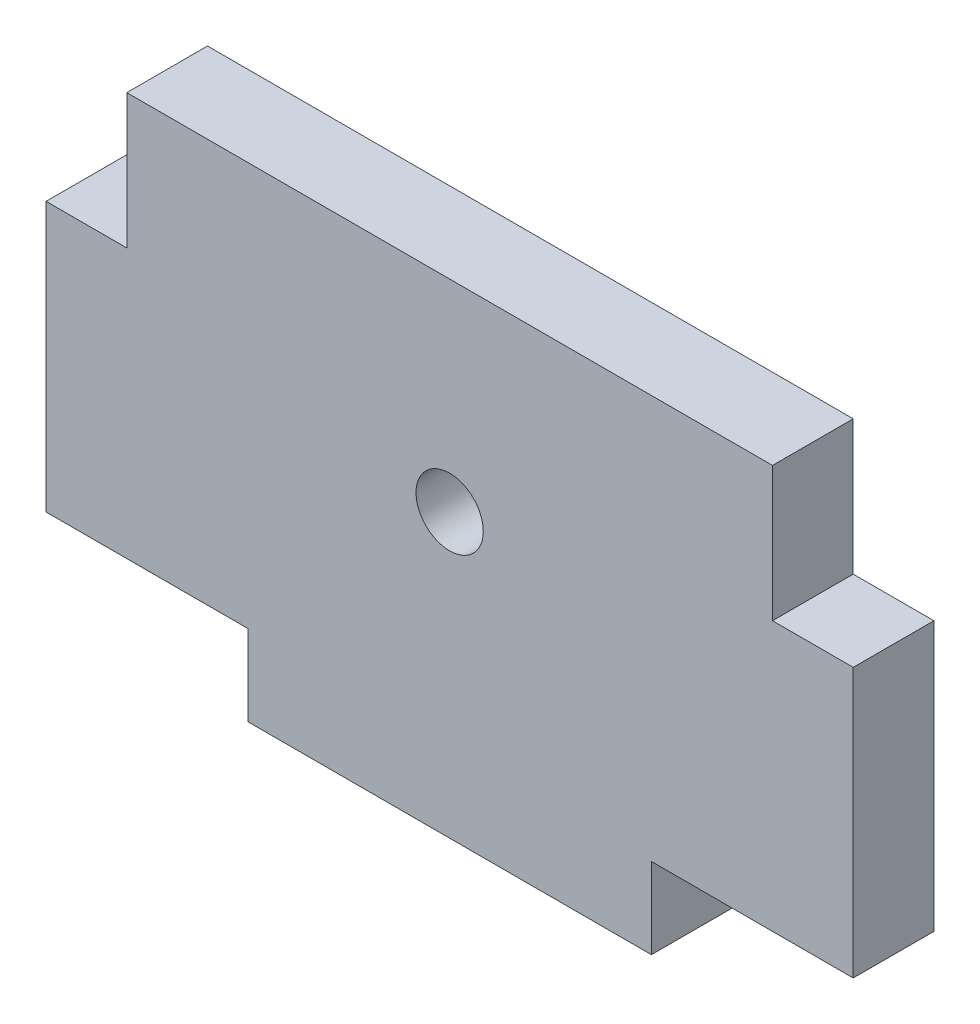
from build123d import *

# Parameters (mm, degrees)
SKETCH1_W           = 60
SKETCH1_H           = 36
BOSS_EXTRUDE1_DEPTH = 6
SKETCH2_W           = 15
SKETCH2_H           = 6
CUT_EXTRUDE1_DEPTH  = 6
SKETCH3_W           = 6
SKETCH3_H           = 10
CUT_EXTRUDE2_DEPTH  = 6
SKETCH4_R           = 2.5
CUT_EXTRUDE3_DEPTH  = 6


with BuildPart() as part:
    # Sketch1 → Boss-Extrude1 (new body)
    with BuildSketch(Plane.XY):
        with Locations((30, 18)):
            Rectangle(SKETCH1_W, SKETCH1_H)
    extrude(amount=BOSS_EXTRUDE1_DEPTH)

    # Sketch2 → Cut-Extrude1 (cut)
    with BuildSketch(Plane.XY.offset(6)):
        with Locations((7.5, 3)):
            Rectangle(SKETCH2_W, SKETCH2_H)
        with Locations((52.5, 3)):
            Rectangle(SKETCH2_W, SKETCH2_H)
    extrude(amount=-CUT_EXTRUDE1_DEPTH, mode=Mode.SUBTRACT)

    # Sketch3 → Cut-Extrude2 (cut)
    with BuildSketch(Plane.XY.offset(6)):
        with Locations((3, 31)):
            Rectangle(SKETCH3_W, SKETCH3_H)
        with Locations((57, 31)):
            Rectangle(SKETCH3_W, SKETCH3_H)
    extrude(amount=-CUT_EXTRUDE2_DEPTH, mode=Mode.SUBTRACT)

    # Sketch4 → Cut-Extrude3 (cut)
    with BuildSketch(Plane.XY.offset(6)):
        with Locations((30, 21)):
            Circle(SKETCH4_R)
    extrude(amount=-CUT_EXTRUDE3_DEPTH, mode=Mode.SUBTRACT)


solid = part.part
